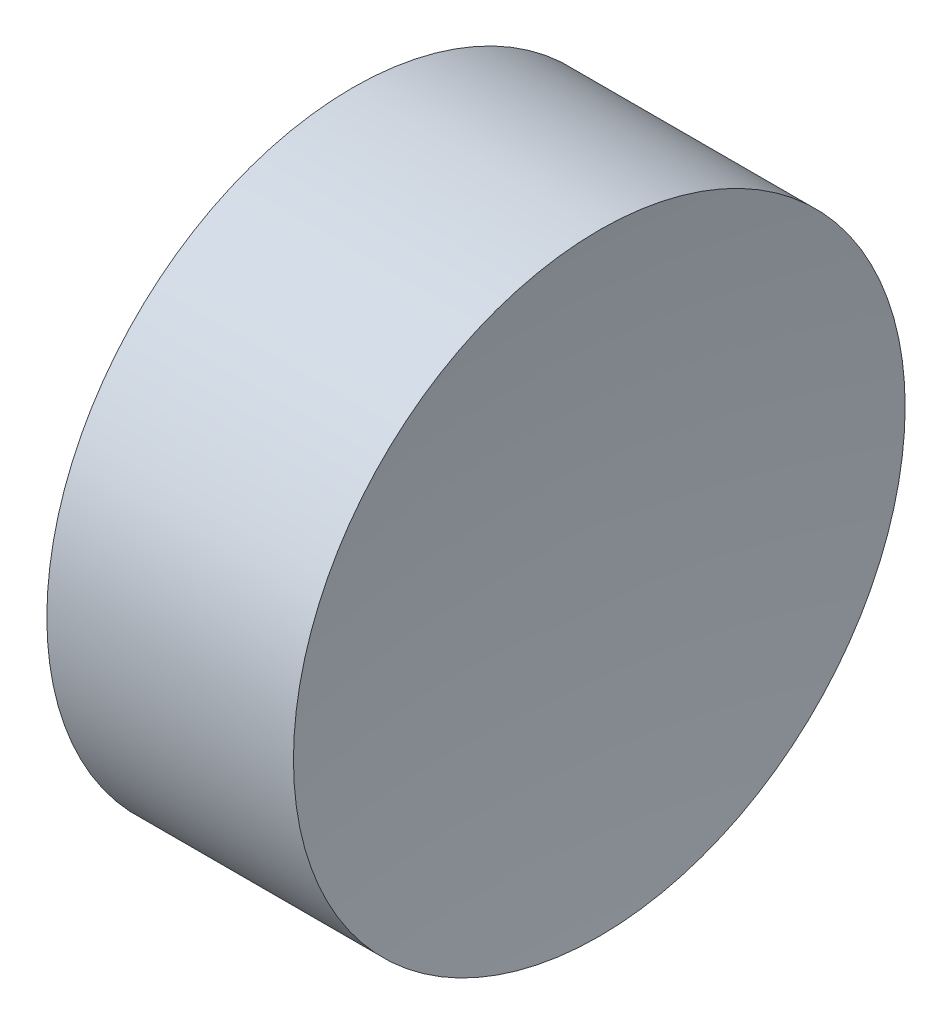
from build123d import *


with BuildPart() as part:
    # 草图1 → 旋转1 (revolve)
    with BuildSketch(Plane.XY, mode=Mode.PRIVATE) as revolve_1_sk:
        with BuildLine():
            Line((12.514118604, 6.522260287), (11.514118604, 6.522260287))
            ThreePointArc((11.514118604, 6.522260287), (11.487160208, 7.274190844), (11.406423449, 8.022260287))
            Line((11.406423449, 8.022260287), (12.014118604, 8.022260287))
            Line((12.014118604, 8.022260287), (12.615851783, 8.022260287))
            ThreePointArc((12.615851783, 8.022260287), (12.538103455, 7.274083464), (12.514118604, 6.522260287))
        make_face()
    revolve(revolve_1_sk.sketch.rotate(Axis((10.612465279, 6.522260287, 0), (1, 0, 0)), 90), axis=Axis((10.612465279, 6.522260287, 0), (1, 0, 0)))  # turned: the seam where the file's is


solid = part.part
